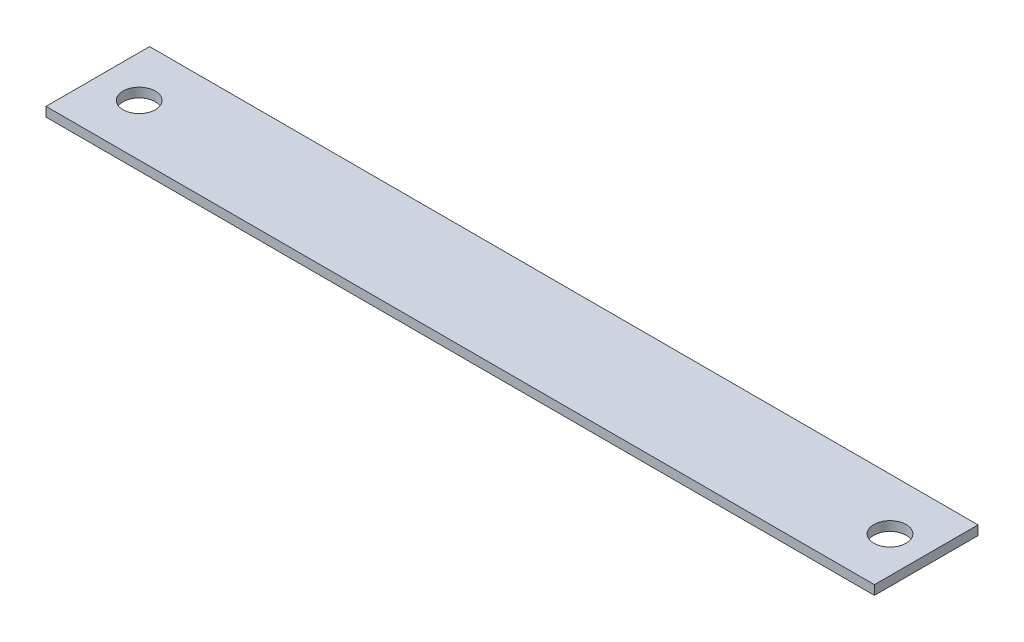
from build123d import *

# Parameters (mm, degrees)
SKETCH1_W           = 203.2
SKETCH1_H           = 25.4
BOSS_EXTRUDE1_DEPTH = 2.286
SKETCH2_R           = 3.96875
CUT_EXTRUDE1_DEPTH  = 3.286


with BuildPart() as part:
    # Sketch1 → Boss-Extrude1 (new body)
    with BuildSketch(Plane(origin=(0, 0, 0), x_dir=(1, 0, 0), z_dir=(0, 1, 0))):
        with Locations((101.6, 12.7)):
            Rectangle(SKETCH1_W, SKETCH1_H)
    extrude(amount=BOSS_EXTRUDE1_DEPTH)

    # Sketch2 → Cut-Extrude1 (cut, through all)
    with BuildSketch(Plane(origin=(0, 2.286, 0), x_dir=(1, 0, 0), z_dir=(0, 1, 0))):
        with Locations((10.16, 12.7)):
            Circle(SKETCH2_R)
        with Locations((194.31, 12.7)):
            Circle(SKETCH2_R)
    extrude(amount=-CUT_EXTRUDE1_DEPTH, mode=Mode.SUBTRACT)


solid = part.part
